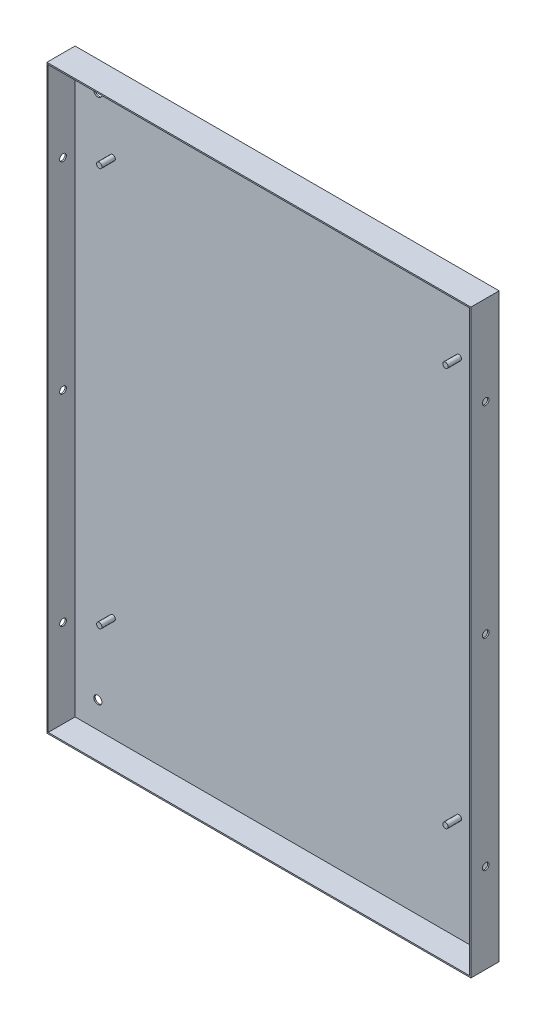
from build123d import *

# Parameters (mm, degrees)
CROQUIS1_W              = 316
CROQUIS1_H              = 433
SALIENTE_EXTRUIR3_DEPTH = 1
CROQUIS2_W              = 314
CROQUIS2_H              = 431
SALIENTE_EXTRUIR4_DEPTH = 20
CROQUIS3_R              = 2
SALIENTE_EXTRUIR5_DEPTH = 10
CROQUIS4_R              = 2.5
CORTAR_EXTRUIR1_DEPTH   = 316
CROQUIS5_R              = 3
CORTAR_EXTRUIR2_DEPTH   = 1


with BuildPart() as part:
    # Croquis1 → Saliente-Extruir3 (new body)
    with BuildSketch(Plane.XY):
        with Locations((-158, 216.5)):
            Rectangle(CROQUIS1_W, CROQUIS1_H)
    extrude(amount=SALIENTE_EXTRUIR3_DEPTH)

    # Croquis2 → Saliente-Extruir4 (add)
    with BuildSketch(Plane.XY.offset(1)):
        Polygon((-315, 433), (-316, 433), (-316, 432), (-316, 1), (-316, 0), (-315, 0), (-1, 0), (0, 0), (0, 1), (0, 432), (0, 433), align=None)
        with Locations((-158, 216.5)):
            Rectangle(CROQUIS2_W, CROQUIS2_H, mode=Mode.SUBTRACT)
    extrude(amount=SALIENTE_EXTRUIR4_DEPTH)

    # Croquis3 → Saliente-Extruir5 (add)
    with BuildSketch(Plane.XY.offset(1)):
        with Locations((-287, 376)):
            Circle(CROQUIS3_R)
        with Locations((-29, 376)):
            Circle(CROQUIS3_R)
        with Locations((-287, 79)):
            Circle(CROQUIS3_R)
        with Locations((-29, 79)):
            Circle(CROQUIS3_R)
    extrude(amount=SALIENTE_EXTRUIR5_DEPTH)

    # Croquis4 → Cortar-Extruir1 (cut)
    with BuildSketch(Plane(origin=(0, 0, 0), x_dir=(0, 0, -1), z_dir=(1, 0, 0))):
        with Locations((-10, 366.5)):
            Circle(CROQUIS4_R)
        with Locations((-10, 66.5)):
            Circle(CROQUIS4_R)
        with Locations((-10, 216.5)):
            Circle(CROQUIS4_R)
    extrude(amount=-CORTAR_EXTRUIR1_DEPTH, mode=Mode.SUBTRACT)

    # Croquis5 → Cortar-Extruir2 (cut)
    with BuildSketch(Plane.XY.offset(1)):
        with Locations((-298, 412.5)):
            Circle(CROQUIS5_R)
        with Locations((-298, 20.5)):
            Circle(CROQUIS5_R)
        with Locations((-18, 412.5)):
            Circle(CROQUIS5_R)
        with Locations((-18, 20.5)):
            Circle(CROQUIS5_R)
    extrude(amount=-CORTAR_EXTRUIR2_DEPTH, mode=Mode.SUBTRACT)


solid = part.part
